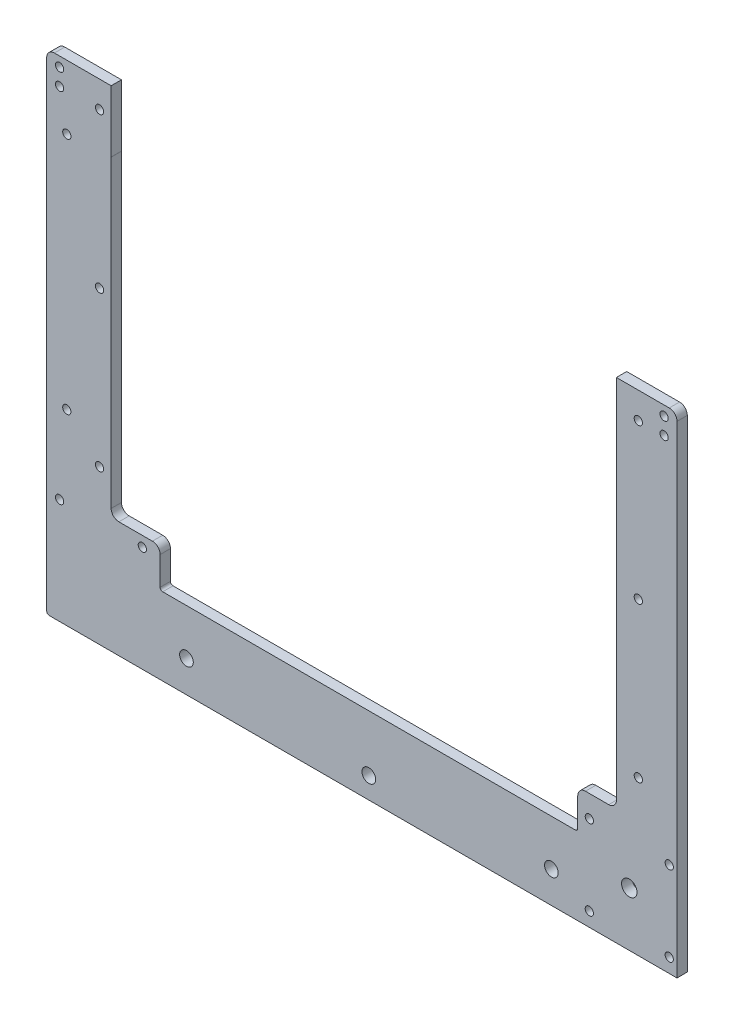
from build123d import *

# Parameters (mm, degrees)
RESSALTO_EXTRUS_O1_DEPTH = 4
FURO_COM_FOLGA_DE_M31_D  = 3.2
FILETE1_R                = 3
M3_CLEARANCE_HOLE1_D     = 3.2
FURO_COM_FOLGA_DE_M32_D  = 2.87
M3_CLEARANCE_HOLE2_D     = 3.2
SKETCH3_W                = 27.430623534
SKETCH3_H                = 190
CUT_EXTRUDE1_DEPTH       = 10
BOSS_EXTRUDE1_DEPTH      = 4
FILLET3_R                = 3
BOSS_EXTRUDE3_DEPTH      = 4
M3_CLEARANCE_HOLE4_D     = 3.2
FILLET5_R                = 3
M5_CLEARANCE_HOLE1_D     = 5.3
SKETCH15_R               = 3
CUT_EXTRUDE6_DEPTH       = 5
SKETCH17_W               = 196
SKETCH17_H               = 23.942856981
CUT_EXTRUDE8_DEPTH       = 5
M3_CLEARANCE_HOLE5_D     = 3.2


with BuildPart() as part:
    # Esboço1 → Ressalto-extrusão1 (new body)
    with BuildSketch(Plane.XY):
        with BuildLine():
            Line((168.243612151, -138.115636704), (-79.756387849, -138.115636704))
            ThreePointArc((-79.756387849, -138.115636704), (-80.46349463, -137.822743485), (-80.756387849, -137.115636704))
            Line((-80.756387849, -137.115636704), (-80.756387849, 48.884363296))
            ThreePointArc((-80.756387849, 48.884363296), (-79.877708192, 51.005683639), (-77.756387849, 51.884363296))
            Line((-77.756387849, 51.884363296), (166.243612151, 51.884363296))
            ThreePointArc((166.243612151, 51.884363296), (168.364932495, 51.005683639), (169.243612151, 48.884363296))
            Line((169.243612151, 48.884363296), (169.243612151, -137.115636704))
            ThreePointArc((169.243612151, -137.115636704), (168.950718933, -137.822743485), (168.243612151, -138.115636704))
        make_face()
        with BuildLine():
            Line((-36.756387849, -93.115636704), (-55.756387849, -93.115636704))
            Line((-55.756387849, -93.115636704), (-55.756387849, -79.115636704))
            Line((-55.756387849, -79.115636704), (-55.756387849, 27.884363296))
            ThreePointArc((-55.756387849, 27.884363296), (-54.877708192, 30.005683639), (-52.756387849, 30.884363296))
            Line((-52.756387849, 30.884363296), (141.243612151, 30.884363296))
            ThreePointArc((141.243612151, 30.884363296), (143.364932495, 30.005683639), (144.243612151, 27.884363296))
            Line((144.243612151, 27.884363296), (144.243612151, -79.115636704))
            Line((144.243612151, -79.115636704), (144.243612151, -93.115636704))
            Line((144.243612151, -93.115636704), (125.243612151, -93.115636704))
            Line((125.243612151, -93.115636704), (125.243612151, -107.115636704))
            ThreePointArc((125.243612151, -107.115636704), (124.950718933, -107.822743485), (124.243612151, -108.115636704))
            Line((124.243612151, -108.115636704), (-35.756387849, -108.115636704))
            ThreePointArc((-35.756387849, -108.115636704), (-36.46349463, -107.822743485), (-36.756387849, -107.115636704))
            Line((-36.756387849, -107.115636704), (-36.756387849, -93.115636704))
        make_face(mode=Mode.SUBTRACT)
    extrude(amount=RESSALTO_EXTRUS_O1_DEPTH)

    # Furo com folga de M31 (through all)
    with Locations(Plane(origin=(0, 0, 0), x_dir=(-1, 0, 0), z_dir=(0, 0, -1))):
        with Locations((-148.743612151, -78.347886704), (-148.743612151, -18.347886704), (-148.743612151, 41.652113296), (60.256387849, 41.652113296), (60.256387849, -18.347886704), (60.256387849, -78.347886704), (72.956387849, 27.018533744), (72.956387849, -65.481466256), (19.656387849, -65.481466256), (19.656387849, 27.018533744)):
            Hole(FURO_COM_FOLGA_DE_M31_D / 2)

    # Filete1
    filete1_edges = [part.edges().sort_by_distance(p)[0] for p in [
        (-55.756387849, -93.115636704, 2),
        (-36.756387849, -93.115636704, 2),
        (125.243612151, -93.115636704, 2),
        (144.243612151, -93.115636704, 2),
    ]]
    fillet(filete1_edges, radius=FILETE1_R)

    # M3 Clearance Hole1 (through all)
    with Locations(Plane(origin=(0, 0, 0), x_dir=(-1, 0, 0), z_dir=(0, 0, -1))):
        with Locations((-164.230041881, -97.102981335), (43.669958119, -97.102981335), (75.742817578, -97.102981335)):
            Hole(M3_CLEARANCE_HOLE1_D / 2)

    # Furo com folga de M32 (through all)
    with Locations(Plane.XY.offset(4)):
        with Locations((44.243612151, 46.98714614)):
            Hole(FURO_COM_FOLGA_DE_M32_D / 2)

    # M3 Clearance Hole2 (through all)
    with Locations(Plane.XY.offset(4)):
        with Locations((161.560317261, 35.480164232), (161.560317261, 4.480164232)):
            Hole(M3_CLEARANCE_HOLE2_D / 2)

    # Sketch3 → Cut-Extrude1 (cut)
    with BuildSketch(Plane.XY.offset(4)):
        with Locations((169.958923918, -43.115636704)):
            Rectangle(SKETCH3_W, SKETCH3_H)
    extrude(amount=-CUT_EXTRUDE1_DEPTH, mode=Mode.SUBTRACT)

    # Sketch5 → Boss-Extrude1 (add)
    with BuildSketch(Plane(origin=(0, 0, 0), x_dir=(-1, 0, 0), z_dir=(0, 0, -1))):
        with BuildLine():
            Line((-145.240285588, -97.500155699), (-140.243612151, -97.500155699))
            Line((-140.243612151, -97.500155699), (-140.243612151, 27.941506315))
            ThreePointArc((-140.243612151, 27.941506315), (-139.345176367, 30.025791601), (-137.244155982, 30.884363296))
            Line((-137.244155982, 30.884363296), (-145.240285588, 30.884363296))
            Line((-145.240285588, 30.884363296), (-145.240285588, -97.500155699))
        make_face()
    extrude(amount=-BOSS_EXTRUDE1_DEPTH)

    # Fillet3
    fillet3_edges = [part.edges().sort_by_distance(p)[0] for p in [
        (156.243612151, 51.884363296, 2),
    ]]
    fillet(fillet3_edges, radius=FILLET3_R)

    # Sketch10 → Boss-Extrude3 (add)
    with BuildSketch(Plane(origin=(0, 0, 0), x_dir=(-1, 0, 0), z_dir=(0, 0, -1))):
        with BuildLine():
            Line((-156.243612151, -138.115636704), (-156.243612151, 48.884363296))
            ThreePointArc((-156.243612151, 48.884363296), (-155.364932495, 51.005683639), (-153.243612151, 51.884363296))
            Line((-153.243612151, 51.884363296), (-163.743612151, 51.884363296))
            Line((-163.743612151, 51.884363296), (-163.743612151, -138.115636704))
            Line((-163.743612151, -138.115636704), (-156.243612151, -138.115636704))
        make_face()
    extrude(amount=-BOSS_EXTRUDE3_DEPTH)

    # M3 Clearance Hole4 (through all)
    with Locations(Plane(origin=(0, 0, 0), x_dir=(-1, 0, 0), z_dir=(0, 0, -1))):
        with Locations((-160.743612151, -101.615636704), (-160.743612151, -132.615636704), (-129.743612151, -132.615636704), (-129.743612151, -101.615636704)):
            Hole(M3_CLEARANCE_HOLE4_D / 2)

    # Fillet5
    fillet5_edges = [part.edges().sort_by_distance(p)[0] for p in [
        (140.243612151, -93.115636704, 2),
        (163.743612151, 51.884363296, 2),
    ]]
    fillet(fillet5_edges, radius=FILLET5_R)

    # M5 Clearance Hole1 (through all)
    with Locations(Plane(origin=(0, 0, 0), x_dir=(-1, 0, 0), z_dir=(0, 0, -1))):
        with Locations((-115.03361215, -125.8856367), (26.54638785, -125.8856367), (-44.189907873, -129.865636704)):
            Hole(M5_CLEARANCE_HOLE1_D / 2)

    # Sketch15 → Cut-Extrude6 (cut, through all)
    with BuildSketch(Plane(origin=(0, 0, 0), x_dir=(-1, 0, 0), z_dir=(0, 0, -1))):
        with Locations((-145.243612151, -117.115636704)):
            Circle(SKETCH15_R)
    extrude(amount=-CUT_EXTRUDE6_DEPTH, mode=Mode.SUBTRACT)

    # Sketch17 → Cut-Extrude8 (cut)
    with BuildSketch(Plane(origin=(0, 0, 0), x_dir=(-1, 0, 0), z_dir=(0, 0, -1))):
        with Locations((-42.243612151, 39.912934806)):
            Rectangle(SKETCH17_W, SKETCH17_H)
    extrude(amount=-CUT_EXTRUDE8_DEPTH, mode=Mode.SUBTRACT)

    # M3 Clearance Hole5 (through all)
    with Locations(Plane.XY.offset(4)):
        with Locations((-75.756387849, 41.652113296), (-75.756387849, 48.152113296), (158.743612151, 48.152113296), (158.743612151, 41.652113296)):
            Hole(M3_CLEARANCE_HOLE5_D / 2)


solid = part.part
